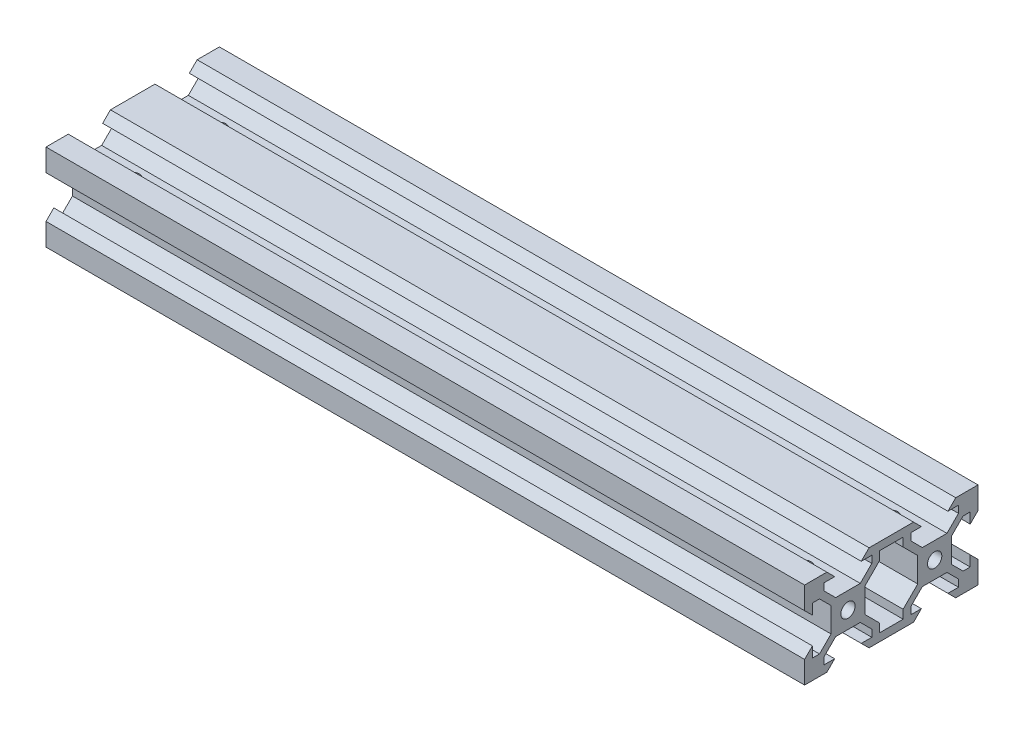
from build123d import *

# Parameters (mm, degrees)
SKETCH1_W           = 175
SKETCH1_H           = 40
BOSS_EXTRUDE1_DEPTH = 20
SKETCH7_R           = 1.65
CUT_EXTRUDE13_DEPTH = 176
SKETCH17_R          = 1.65
SKETCH17_R_2        = 1.55
BOSS_EXTRUDE2_DEPTH = 15
SKETCH16_R          = 1.5
CUT_EXTRUDE11_DEPTH = 14.9


with BuildPart() as part:
    # Sketch1 → Boss-Extrude1 (new body)
    with BuildSketch(Plane(origin=(0, 0, 0), x_dir=(1, 0, 0), z_dir=(0, 1, 0))):
        Rectangle(SKETCH1_W, SKETCH1_H)
    extrude(amount=BOSS_EXTRUDE1_DEPTH)

    # Sketch7 → Cut-Extrude13 (cut, through all)
    with BuildSketch(Plane(origin=(87.5, 0, 0), x_dir=(0, 0, -1), z_dir=(1, 0, 0))):
        Polygon((-12.839339828, 13.9), (-7.159339828, 13.9), (-4.499339828, 16.56), (-4.499339828, 18.2), (-6.934339828, 18.2), (-5.134339828, 20), (-14.864339828, 20), (-13.064339828, 18.2), (-15.499339828, 18.2), (-15.499339828, 16.56), align=None)
        Polygon((-18.2, 13.064339828), (-20, 14.864339828), (-20, 5.134339828), (-18.2, 6.934339828), (-18.2, 4.499339828), (-16.56, 4.499339828), (-13.9, 7.159339828), (-13.9, 12.839339828), (-16.56, 15.499339828), (-18.2, 15.499339828), align=None)
        Polygon((-13.064339828, 1.798679656), (-14.863019485, 0), (-5.135660172, 0), (-6.934339828, 1.798679656), (-4.499339828, 1.798679656), (-4.499339828, 3.438679656), (-7.159339828, 6.098679656), (-12.839339828, 6.098679656), (-15.499339828, 3.438679656), (-15.499339828, 1.798679656), align=None)
        Polygon((6.098679656, 12.839339828), (6.098679656, 7.159339828), (2.73, 3.790660172), (2.73, 1.798679656), (-2.73, 1.798679656), (-2.73, 3.790660172), (-6.098679656, 7.159339828), (-6.098679656, 12.839339828), (-2.73, 16.208019485), (-2.73, 18.2), (2.73, 18.2), (2.73, 16.208019485), align=None)
        Polygon((5.135660172, 0), (14.863019485, 0), (13.064339828, 1.798679656), (15.499339828, 1.798679656), (15.499339828, 3.438679656), (12.839339828, 6.098679656), (7.159339828, 6.098679656), (4.499339828, 3.438679656), (4.499339828, 1.798679656), (6.934339828, 1.798679656), align=None)
        Polygon((20, 5.134339828), (20, 14.864339828), (18.2, 13.064339828), (18.2, 15.499339828), (16.56, 15.499339828), (13.9, 12.839339828), (13.9, 7.159339828), (16.56, 4.499339828), (18.2, 4.499339828), (18.2, 6.934339828), align=None)
        Polygon((14.864339828, 20), (5.134339828, 20), (6.934339828, 18.2), (4.499339828, 18.2), (4.499339828, 16.56), (7.159339828, 13.9), (12.839339828, 13.9), (15.499339828, 16.56), (15.499339828, 18.2), (13.064339828, 18.2), align=None)
        with Locations((-10, 10)):
            Circle(SKETCH7_R)
        with Locations((10, 10)):
            Circle(SKETCH7_R)
    extrude(amount=-CUT_EXTRUDE13_DEPTH, mode=Mode.SUBTRACT)

    # Sketch17 → Boss-Extrude2 (add)
    with BuildSketch(Plane.ZY.offset(87.5)):
        with Locations((-10, 10)):
            Circle(SKETCH17_R)
        with Locations((-10, 10)):
            Circle(SKETCH17_R_2, mode=Mode.SUBTRACT)
        with Locations((10, 10)):
            Circle(SKETCH17_R)
        with Locations((10, 10)):
            Circle(SKETCH17_R_2, mode=Mode.SUBTRACT)
    extrude(amount=-BOSS_EXTRUDE2_DEPTH)

    # Sketch16 → Cut-Extrude11 (cut, through all)
    with BuildSketch(Plane(origin=(0, 13.9, 0), x_dir=(1, 0, 0), z_dir=(0, 1, 0))):
        with Locations((77.5, -9.999339828)):
            Circle(SKETCH16_R)
        with Locations((77.5, 9.999339828)):
            Circle(SKETCH16_R)
    cut_extrude11 = extrude(amount=-CUT_EXTRUDE11_DEPTH, mode=Mode.SUBTRACT)

    # Mirror1: Cut-Extrude11 across plane
    add(cut_extrude11.mirror(Plane.ZY), mode=Mode.SUBTRACT)


solid = part.part
